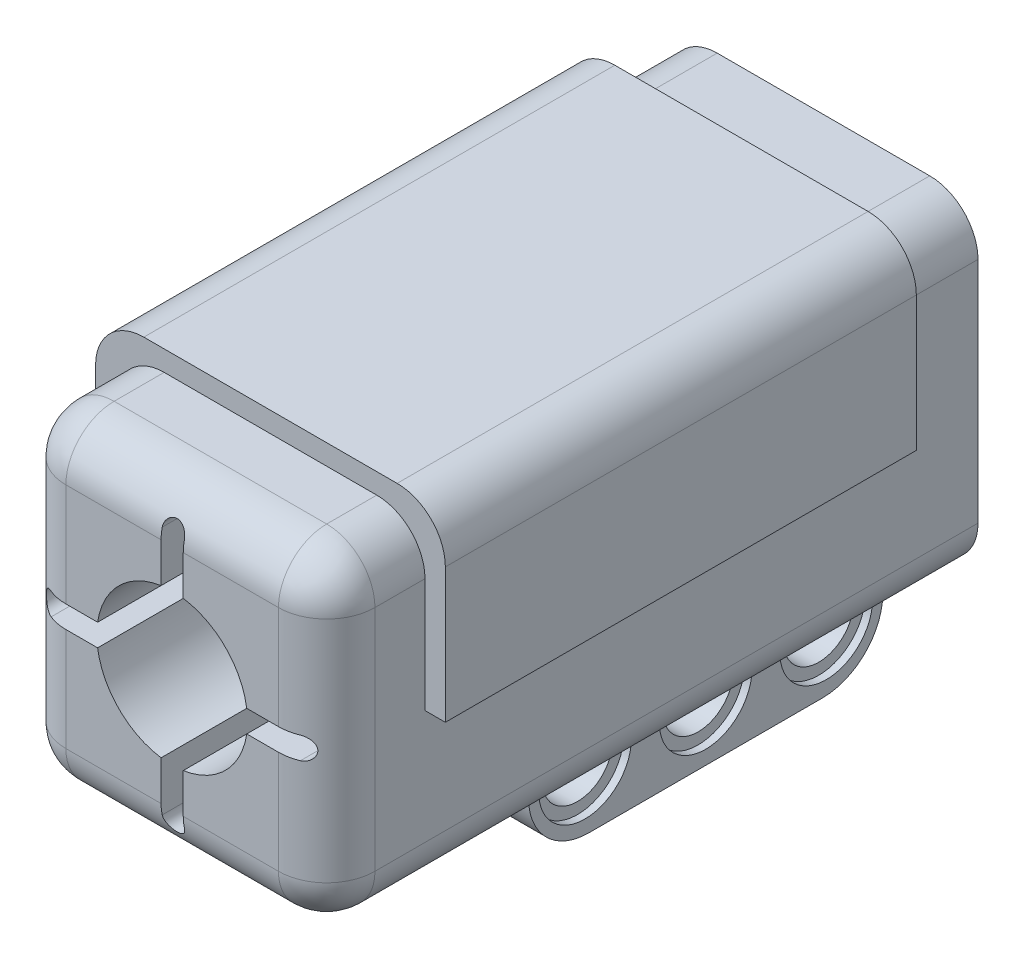
from build123d import *

# Parameters (mm, degrees)
SKETCH1_W           = 20.5
SKETCH1_H           = 21.55
BOSS_EXTRUDE1_DEPTH = 43.2
FILLET1_R           = 3.2
BOSS_EXTRUDE2_DEPTH = 31.24
CUT_EXTRUDE1_DEPTH  = 10
SKETCH4_W           = 7.87
SKETCH4_H           = 23.5
BOSS_EXTRUDE3_DEPTH = 8
CUT_EXTRUDE2_REACH  = 17.535
SKETCH5_R           = 2.325
SKETCH7_R           = 3.075
CUT_EXTRUDE3_DEPTH  = 0.5
SKETCH8_R           = 3.075
CUT_EXTRUDE5_DEPTH  = 0.5
FILLET2_R           = 4
SKETCH9_W           = 12.28
SKETCH9_H           = 14.55
CUT_EXTRUDE6_DEPTH  = 15
FILLET3_R           = 1


with BuildPart() as part:
    # Sketch1 → Boss-Extrude1 (new body)
    with BuildSketch(Plane.XY):
        with Locations((10.25, 10.775)):
            Rectangle(SKETCH1_W, SKETCH1_H)
    extrude(amount=BOSS_EXTRUDE1_DEPTH)

    # Fillet1
    fillet1_edges = [part.edges().sort_by_distance(p)[0] for p in [
        (20.5, 10.775, 43.2),
        (10.25, 21.55, 43.2),
        (0, 10.775, 43.2),
        (10.25, 0, 43.2),
        (0, 21.55, 21.6),
        (20.5, 21.55, 21.6),
        (20.5, 0, 21.6),
        (0, 0, 21.6),
    ]]
    fillet(fillet1_edges, radius=FILLET1_R)

    # Sketch2 → Boss-Extrude2 (add)
    with BuildSketch(Plane(origin=(0, 0, 5.44), x_dir=(-1, 0, 0), z_dir=(0, 0, -1))):
        with BuildLine():
            Line((-20.5, 10.775), (-21.85, 10.775))
            Line((-21.85, 10.775), (-21.85, 19.7))
            ThreePointArc((-21.85, 19.7), (-20.9127417, 21.9627417), (-18.65, 22.9))
            Line((-18.65, 22.9), (-1.85, 22.9))
            ThreePointArc((-1.85, 22.9), (0.4127417, 21.9627417), (1.35, 19.7))
            Line((1.35, 19.7), (1.35, 10.775))
            Line((1.35, 10.775), (0, 10.775))
            Line((0, 10.775), (0, 18.35))
            ThreePointArc((0, 18.35), (-0.9372583, 20.6127417), (-3.2, 21.55))
            Line((-3.2, 21.55), (-17.3, 21.55))
            ThreePointArc((-17.3, 21.55), (-19.5627417, 20.6127417), (-20.5, 18.35))
            Line((-20.5, 18.35), (-20.5, 10.775))
        make_face()
    extrude(amount=-BOSS_EXTRUDE2_DEPTH)

    # Sketch3 → Cut-Extrude1 (cut)
    with BuildSketch(Plane.XY.offset(43.2)):
        with BuildLine():
            Line((15.19568246, 11.51), (18.515, 11.51))
            ThreePointArc((18.515, 11.51), (19.25, 10.775), (18.515, 10.04))
            Line((18.515, 10.04), (15.19568246, 10.04))
            ThreePointArc((15.19568246, 10.04), (13.785533906, 7.239466094), (10.985, 5.82931754))
            Line((10.985, 5.82931754), (10.985, 2.51))
            ThreePointArc((10.985, 2.51), (10.25, 1.775), (9.515, 2.51))
            Line((9.515, 2.51), (9.515, 5.82931754))
            ThreePointArc((9.515, 5.82931754), (6.714466094, 7.239466094), (5.30431754, 10.04))
            Line((5.30431754, 10.04), (1.985, 10.04))
            ThreePointArc((1.985, 10.04), (1.25, 10.775), (1.985, 11.51))
            Line((1.985, 11.51), (5.30431754, 11.51))
            ThreePointArc((5.30431754, 11.51), (6.714466094, 14.310533906), (9.515, 15.72068246))
            Line((9.515, 15.72068246), (9.515, 19.04))
            ThreePointArc((9.515, 19.04), (10.25, 19.775), (10.985, 19.04))
            Line((10.985, 19.04), (10.985, 15.72068246))
            ThreePointArc((10.985, 15.72068246), (13.785533906, 14.310533906), (15.19568246, 11.51))
        make_face()
    extrude(amount=-CUT_EXTRUDE1_DEPTH, mode=Mode.SUBTRACT)

    # Sketch4 → Boss-Extrude3 (add)
    with BuildSketch(Plane.XZ):
        with Locations((10.25, 11.75)):
            Rectangle(SKETCH4_W, SKETCH4_H)
    extrude(amount=BOSS_EXTRUDE3_DEPTH)

    # Sketch5 → Cut-Extrude2 (cut, up to next)
    with BuildSketch(Plane(origin=(14.185, 0, 0), x_dir=(0, 0, -1), z_dir=(1, 0, 0)), mode=Mode.PRIVATE) as cut_extrude2_sk1:
        with Locations((-19.75, -4)):
            Circle(SKETCH5_R)
    cut_extrude2_tool1 = extrude(cut_extrude2_sk1.sketch, amount=-CUT_EXTRUDE2_REACH, mode=Mode.PRIVATE) & part.part
    add(cut_extrude2_tool1.solids().sort_by_distance((14.185, -4, 19.75))[0], mode=Mode.SUBTRACT)
    # Sketch5 → Cut-Extrude2 (cut, up to next)
    with BuildSketch(Plane(origin=(14.185, 0, 0), x_dir=(0, 0, -1), z_dir=(1, 0, 0)), mode=Mode.PRIVATE) as cut_extrude2_sk2:
        with Locations((-11.75, -4)):
            Circle(SKETCH5_R)
    cut_extrude2_tool2 = extrude(cut_extrude2_sk2.sketch, amount=-CUT_EXTRUDE2_REACH, mode=Mode.PRIVATE) & part.part
    add(cut_extrude2_tool2.solids().sort_by_distance((14.185, -4, 11.75))[0], mode=Mode.SUBTRACT)
    # Sketch5 → Cut-Extrude2 (cut, up to next)
    with BuildSketch(Plane(origin=(14.185, 0, 0), x_dir=(0, 0, -1), z_dir=(1, 0, 0)), mode=Mode.PRIVATE) as cut_extrude2_sk3:
        with Locations((-3.75, -4)):
            Circle(SKETCH5_R)
    cut_extrude2_tool3 = extrude(cut_extrude2_sk3.sketch, amount=-CUT_EXTRUDE2_REACH, mode=Mode.PRIVATE) & part.part
    add(cut_extrude2_tool3.solids().sort_by_distance((14.185, -4, 3.75))[0], mode=Mode.SUBTRACT)

    # Sketch7 → Cut-Extrude3 (cut)
    with BuildSketch(Plane(origin=(14.185, 0, 0), x_dir=(0, 0, -1), z_dir=(1, 0, 0))):
        with Locations((-19.75, -4)):
            Circle(SKETCH7_R)
        with Locations((-11.75, -4)):
            Circle(SKETCH7_R)
        with Locations((-3.75, -4)):
            Circle(SKETCH7_R)
    extrude(amount=-CUT_EXTRUDE3_DEPTH, mode=Mode.SUBTRACT)

    # Sketch8 → Cut-Extrude5 (cut)
    with BuildSketch(Plane.ZY.offset(-6.315)):
        with Locations((3.75, -4)):
            Circle(SKETCH8_R)
        with Locations((11.75, -4)):
            Circle(SKETCH8_R)
        with Locations((19.75, -4)):
            Circle(SKETCH8_R)
    extrude(amount=-CUT_EXTRUDE5_DEPTH, mode=Mode.SUBTRACT)

    # Fillet2
    fillet2_edges = [part.edges().sort_by_distance(p)[0] for p in [
        (10.25, -8, 0),
        (10.25, -8, 23.5),
    ]]
    fillet(fillet2_edges, radius=FILLET2_R)

    # Sketch9 → Cut-Extrude6 (cut)
    with BuildSketch(Plane(origin=(0, 0, 0), x_dir=(-1, 0, 0), z_dir=(0, 0, -1))):
        with Locations((-10.25, 7.775)):
            Rectangle(SKETCH9_W, SKETCH9_H)
    extrude(amount=-CUT_EXTRUDE6_DEPTH, mode=Mode.SUBTRACT)

    # Fillet3
    fillet3_edges = [part.edges().sort_by_distance(p)[0] for p in [
        (16.39, 0.5, 7.5),
        (4.11, 0.5, 7.5),
    ]]
    fillet(fillet3_edges, radius=FILLET3_R)


solid = part.part
